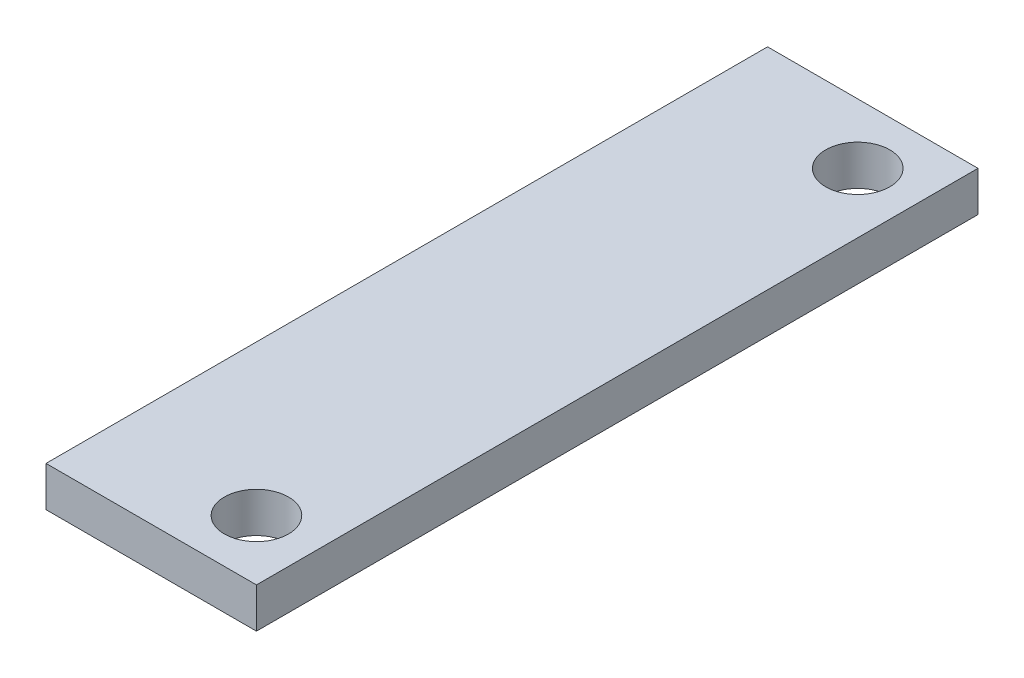
from build123d import *

# Parameters (mm, degrees)
SKETCH_1_W          = 10.5
SKETCH_1_H          = 36
EXTRUDE_1_DEPTH     = 2
SKETCH_2_R          = 1.6
CUT_EXTRUDE_1_DEPTH = 3
SKETCH_3_W          = 9
SKETCH_3_H          = 25
CUT_EXTRUDE_2_DEPTH = 1
SKETCH_6_W          = 0.75
SKETCH_6_H          = 1
CUT_EXTRUDE_3_DEPTH = 0.5
SKETCH_7_W          = 4.3
SKETCH_7_H          = 5.5
CUT_EXTRUDE_4_DEPTH = 0.2


with BuildPart() as part:
    # 草图1 → 凸台-拉伸1 (new body)
    with BuildSketch(Plane(origin=(0, 0, 0), x_dir=(1, 0, 0), z_dir=(0, 1, 0))):
        with Locations((5.25, 18)):
            Rectangle(SKETCH_1_W, SKETCH_1_H)
    extrude(amount=EXTRUDE_1_DEPTH)

    # 草图2 → 切除-拉伸1 (cut, through all)
    with BuildSketch(Plane(origin=(0, 0, 0), x_dir=(-1, 0, 0), z_dir=(0, -1, 0))):
        with Locations((-7.5, 33)):
            Circle(SKETCH_2_R)
        with Locations((-7.5, 3)):
            Circle(SKETCH_2_R)
    extrude(amount=-CUT_EXTRUDE_1_DEPTH, mode=Mode.SUBTRACT)

    # 草图3 → 切除-拉伸2 (cut)
    with BuildSketch(Plane(origin=(0, 0, 0), x_dir=(-1, 0, 0), z_dir=(0, -1, 0))):
        with Locations((-5.25, 18)):
            Rectangle(SKETCH_3_W, SKETCH_3_H)
    extrude(amount=-CUT_EXTRUDE_2_DEPTH, mode=Mode.SUBTRACT)

    # 草图6 → 切除-拉伸3 (cut)
    with BuildSketch(Plane(origin=(0, 0, 0), x_dir=(-1, 0, 0), z_dir=(0, -1, 0))):
        with Locations((-0.375, 17.5)):
            Rectangle(SKETCH_6_W, SKETCH_6_H)
    extrude(amount=-CUT_EXTRUDE_3_DEPTH, mode=Mode.SUBTRACT)

    # 草图7 → 切除-拉伸4 (cut)
    with BuildSketch(Plane(origin=(0, 0, 0), x_dir=(-1, 0, 0), z_dir=(0, -1, 0))):
        with Locations((-3.15, 33.25)):
            Rectangle(SKETCH_7_W, SKETCH_7_H)
    extrude(amount=-CUT_EXTRUDE_4_DEPTH, mode=Mode.SUBTRACT)


solid = part.part
